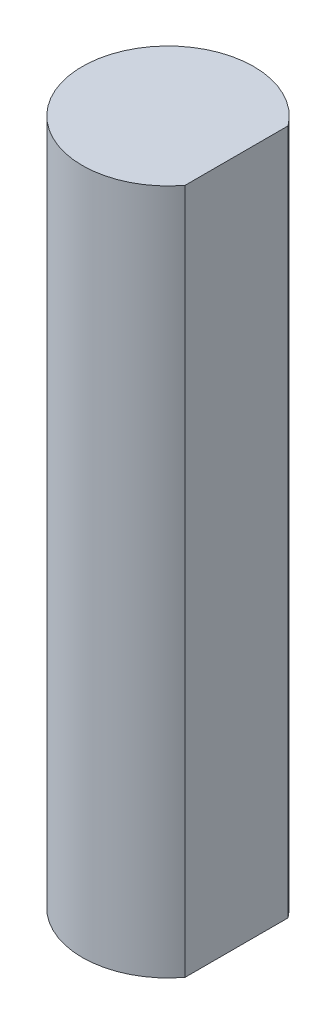
from build123d import *

# Parameters (mm, degrees)
BOSS_EXTRUDE1_DEPTH = 25.4


with BuildPart() as part:
    # Sketch1 → Boss-Extrude1 (new body)
    with BuildSketch(Plane(origin=(0, 0, 0), x_dir=(1, 0, 0), z_dir=(0, 1, 0))):
        with BuildLine():
            Line((2.54, -1.905), (2.54, 1.905))
            ThreePointArc((2.54, 1.905), (-3.175, 0), (2.54, -1.905))
        make_face()
    extrude(amount=BOSS_EXTRUDE1_DEPTH)


solid = part.part
